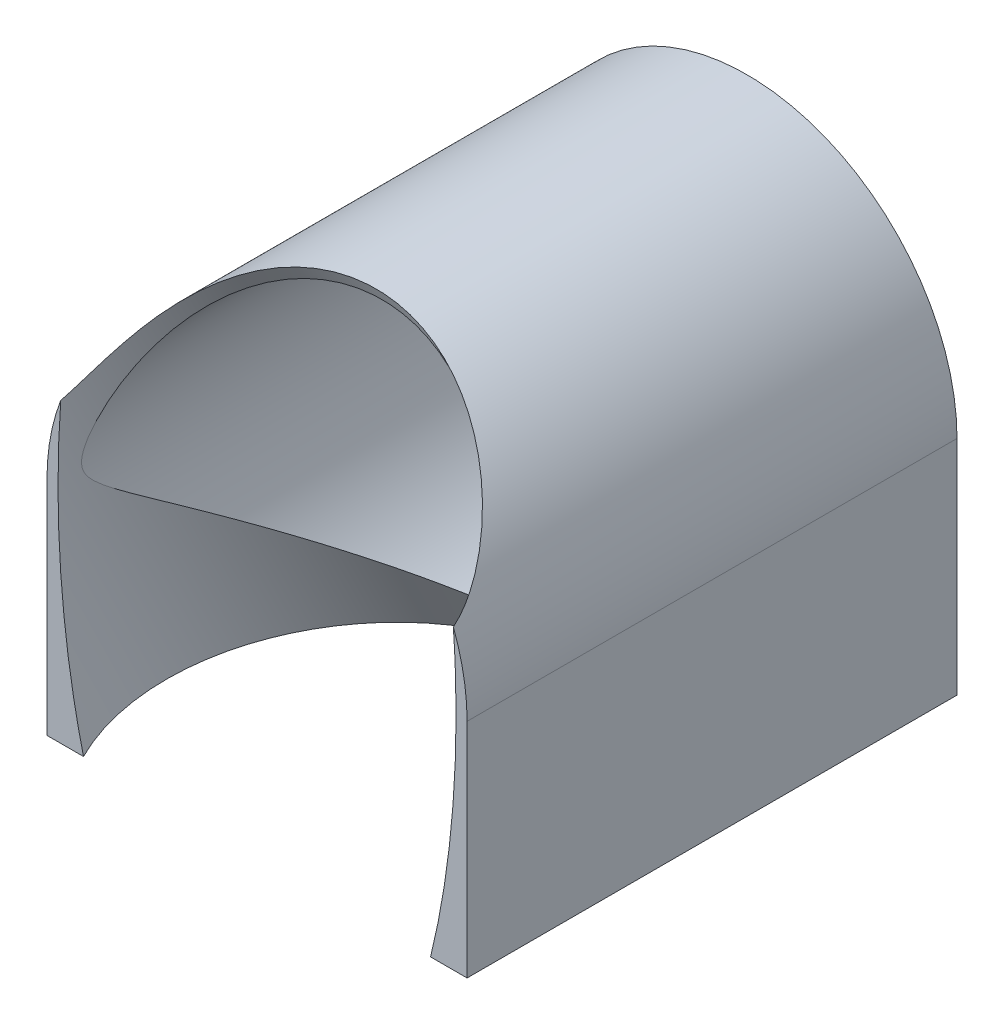
from build123d import *

# Parameters (mm, degrees)
SKETCH1_R           = 17.15
SKETCH1_R_2         = 16.15
BOSS_EXTRUDE1_DEPTH = 40
BOSS_EXTRUDE3_DEPTH = 40
SKETCH2_R           = 16.25
CUT_EXTRUDE1_DEPTH  = 302.327569717


with BuildPart() as part:
    # Sketch1 → Boss-Extrude1 (new body)
    with BuildSketch(Plane.XY):
        with Locations((0, 200)):
            Circle(SKETCH1_R)
        with Locations((0, 200)):
            Circle(SKETCH1_R_2, mode=Mode.SUBTRACT)
    extrude(amount=-BOSS_EXTRUDE1_DEPTH)

    # Sketch4 → Boss-Extrude3 (add)
    with BuildSketch(Plane(origin=(0, 0, -40), x_dir=(-1, 0, 0), z_dir=(0, 0, -1))):
        Polygon((17.15, 182.85), (17.15, 181.85), (-17.15, 181.85), (-17.15, 182.85), (0, 182.85), align=None)
        with BuildLine():
            Line((17.15, 182.85), (17.15, 200))
            ThreePointArc((17.15, 200), (12.126881297, 187.873118703), (0, 182.85))
            Line((0, 182.85), (17.15, 182.85))
        make_face()
        with BuildLine():
            ThreePointArc((0, 182.85), (-12.126881297, 187.873118703), (-17.15, 200))
            Line((-17.15, 200), (-17.15, 182.85))
            Line((-17.15, 182.85), (0, 182.85))
        make_face()
    extrude(amount=-BOSS_EXTRUDE3_DEPTH)

    # Sketch2 → Cut-Extrude1 (cut, through all)
    with BuildSketch(Plane(origin=(0, 401.975230219, 196.056419574), x_dir=(1, 0, 0), z_dir=(0, 0.898794046, 0.438371147))):
        with Locations((0, 87.674229358)):
            Circle(SKETCH2_R)
    extrude(amount=-CUT_EXTRUDE1_DEPTH, mode=Mode.SUBTRACT)


solid = part.part
